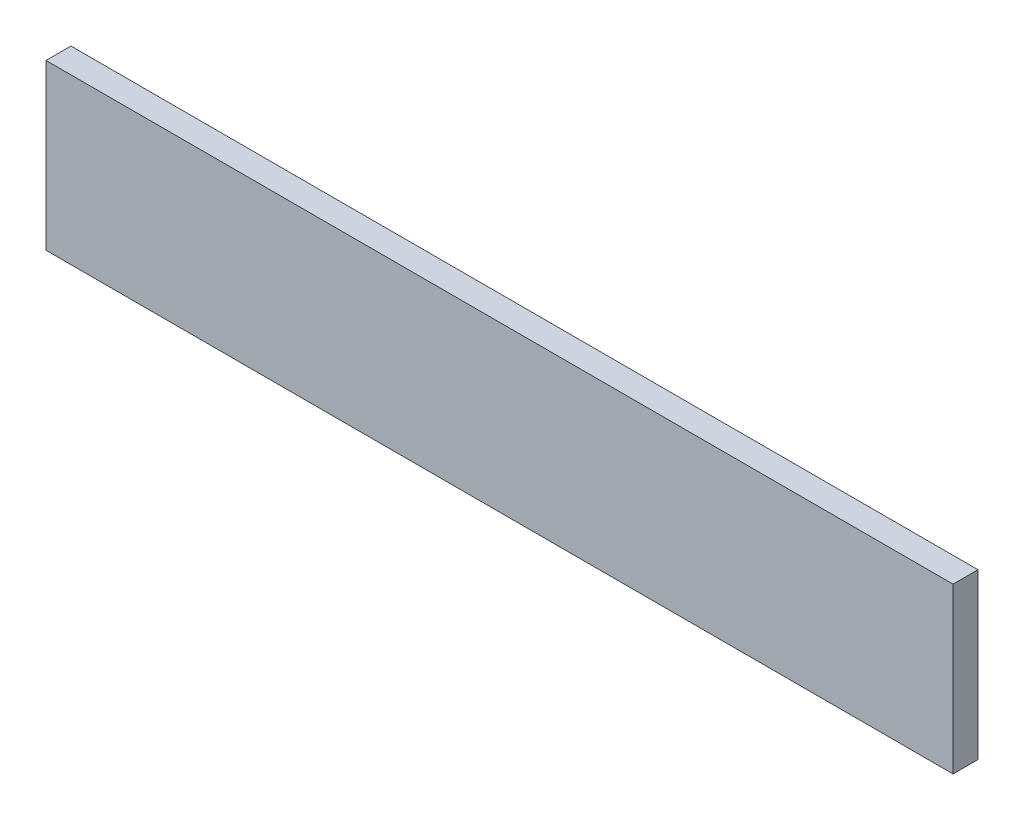
from build123d import *

# Parameters (mm, degrees)
BOSS_EXTRUDE1_DEPTH = 22


with BuildPart() as part:
    # Sketch1 → Boss-Extrude1 (new body)
    with BuildSketch(Plane.XY):
        Polygon((-400, -20), (-400, 0), (-380, 0), (380, 0), (400, 0), (400, -20), (400, -145), (-400, -145), align=None)
    extrude(amount=BOSS_EXTRUDE1_DEPTH)


solid = part.part
